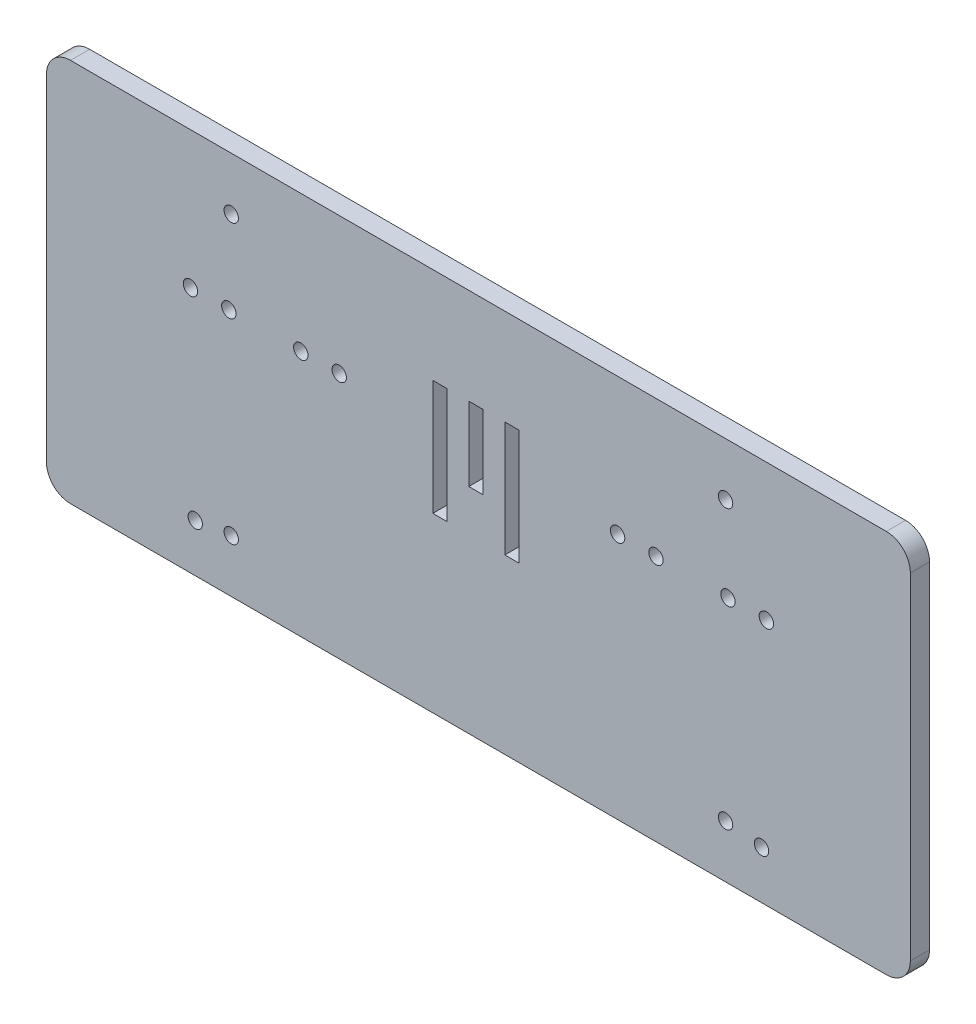
from build123d import *

# Parameters (mm, degrees)
SKETCH1_W           = 180
SKETCH1_H           = 80
SKETCH1_R           = 1.5
BOSS_EXTRUDE1_DEPTH = 4
SKETCH2_W           = 3
SKETCH2_H           = 24
SKETCH2_H_2         = 15.4
CUT_EXTRUDE1_DEPTH  = 4
FILLET1_R           = 5


with BuildPart() as part:
    # Sketch1 → Boss-Extrude1 (new body)
    with BuildSketch(Plane.XY):
        with Locations((2.700642055, -21.117125984)):
            Rectangle(SKETCH1_W, SKETCH1_H)
        with Locations((-57.299357945, -9.617125984)):
            Circle(SKETCH1_R, mode=Mode.SUBTRACT)
        with Locations((62.700642055, -9.617125984)):
            Circle(SKETCH1_R, mode=Mode.SUBTRACT)
        with Locations((61.700642055, -51.117125984)):
            Circle(SKETCH1_R, mode=Mode.SUBTRACT)
        with Locations((-56.299357945, -51.117125984)):
            Circle(SKETCH1_R, mode=Mode.SUBTRACT)
        with Locations((-49.299357945, -9.617125984)):
            Circle(SKETCH1_R, mode=Mode.SUBTRACT)
        with Locations((54.700642055, -9.617125984)):
            Circle(SKETCH1_R, mode=Mode.SUBTRACT)
        with Locations((-34.299357945, -9.617125984)):
            Circle(SKETCH1_R, mode=Mode.SUBTRACT)
        with Locations((-26.299357945, -9.617125984)):
            Circle(SKETCH1_R, mode=Mode.SUBTRACT)
        with Locations((39.700642055, -9.617125984)):
            Circle(SKETCH1_R, mode=Mode.SUBTRACT)
        with Locations((31.700642055, -9.617125984)):
            Circle(SKETCH1_R, mode=Mode.SUBTRACT)
        with Locations((-48.799357945, 7.882874016)):
            Circle(SKETCH1_R, mode=Mode.SUBTRACT)
        with Locations((54.200642055, 7.882874016)):
            Circle(SKETCH1_R, mode=Mode.SUBTRACT)
        with Locations((54.200642055, -50.117125984)):
            Circle(SKETCH1_R, mode=Mode.SUBTRACT)
        with Locations((-48.799357945, -50.117125984)):
            Circle(SKETCH1_R, mode=Mode.SUBTRACT)
    extrude(amount=BOSS_EXTRUDE1_DEPTH)

    # Sketch2 → Cut-Extrude1 (cut)
    with BuildSketch(Plane.XY.offset(4)):
        with Locations((-5.299357945, -13.117125984)):
            Rectangle(SKETCH2_W, SKETCH2_H)
        with Locations((2.200642055, -8.817125984)):
            Rectangle(SKETCH2_W, SKETCH2_H_2)
        with Locations((9.700642055, -13.117125984)):
            Rectangle(SKETCH2_W, SKETCH2_H)
    extrude(amount=-CUT_EXTRUDE1_DEPTH, mode=Mode.SUBTRACT)

    # Fillet1
    fillet1_edges = [part.edges().sort_by_distance(p)[0] for p in [
        (-87.299357945, 18.882874016, 2),
        (92.700642055, 18.882874016, 2),
        (92.700642055, -61.117125984, 2),
        (-87.299357945, -61.117125984, 2),
    ]]
    fillet(fillet1_edges, radius=FILLET1_R)


solid = part.part
